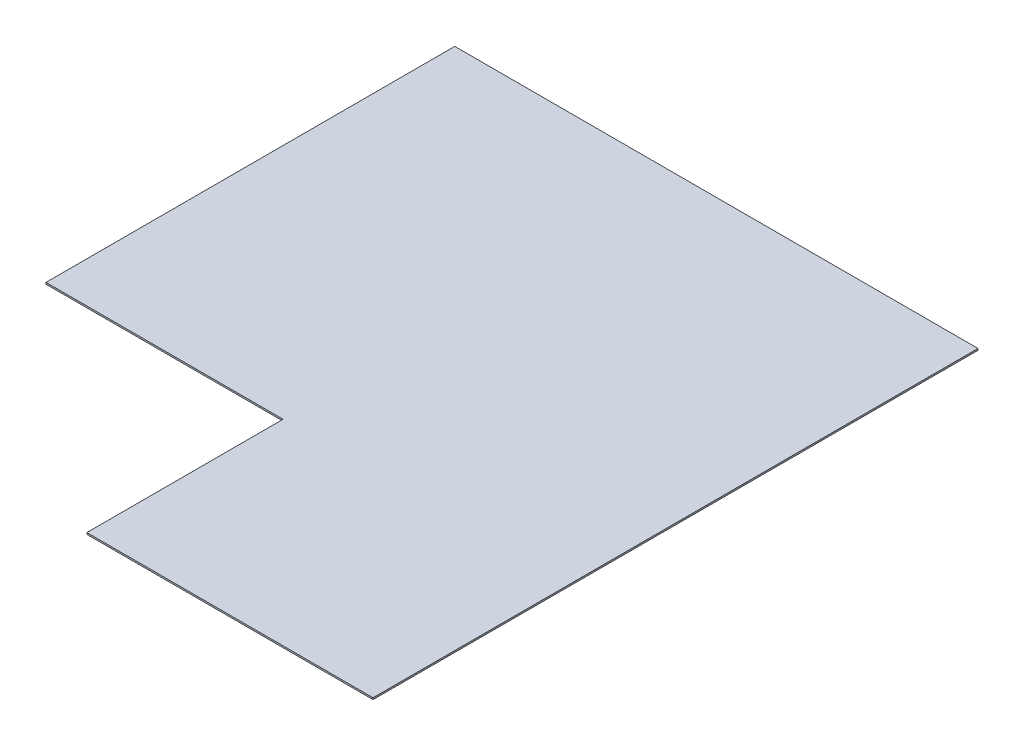
from build123d import *

# Parameters (mm, degrees)
BOSS_EXTRUDE1_DEPTH = 3.175


with BuildPart() as part:
    # Sketch1 → Boss-Extrude1 (new body)
    with BuildSketch(Plane(origin=(0, 0, 0), x_dir=(1, 0, 0), z_dir=(0, 1, 0))):
        Polygon((0, 0), (-1016, 0), (-1016, -793.75), (-555.625, -793.75), (-555.625, -1174.75), (0, -1174.75), align=None)
    extrude(amount=BOSS_EXTRUDE1_DEPTH)


solid = part.part
